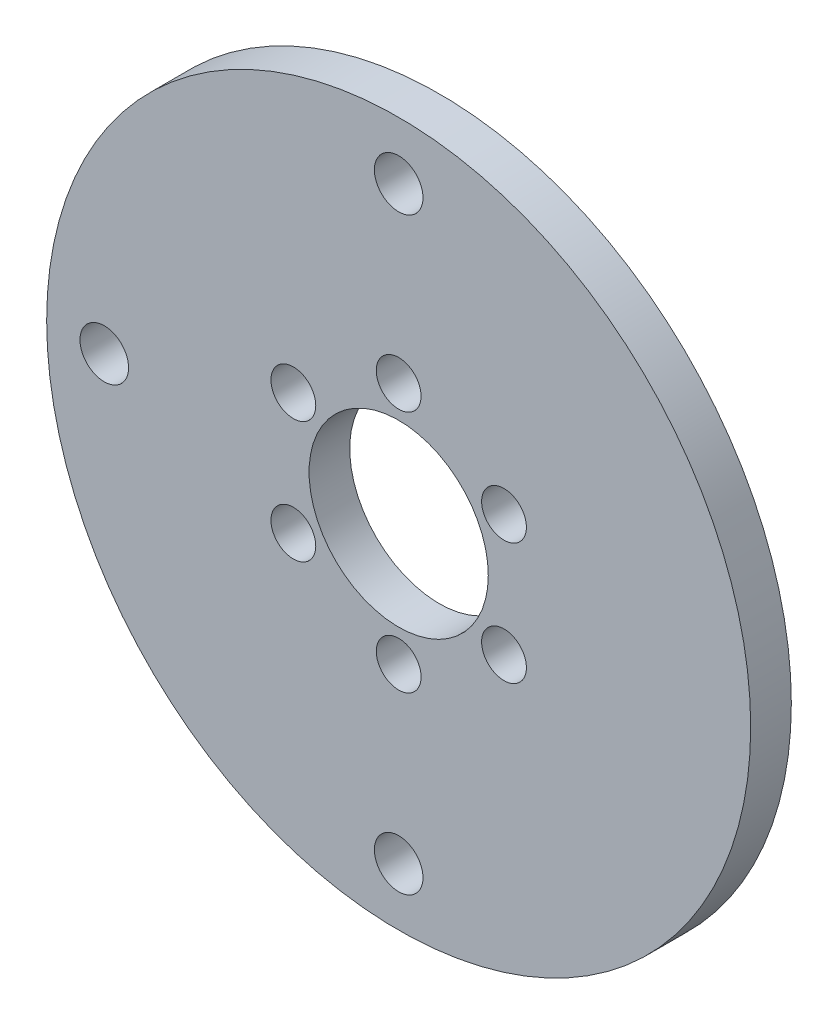
from build123d import *

# Parameters (mm, degrees)
SKETCH1_R           = 27.5
SKETCH1_R_2         = 7
SKETCH1_R_3         = 1.89865
SKETCH1_R_4         = 1.75
BOSS_EXTRUDE1_DEPTH = 3.175


with BuildPart() as part:
    # Sketch1 → Boss-Extrude1 (new body)
    with BuildSketch(Plane.XY):
        Circle(SKETCH1_R)
        Circle(SKETCH1_R_2, mode=Mode.SUBTRACT)
        with Locations((0, 23)):
            Circle(SKETCH1_R_3, mode=Mode.SUBTRACT)
        with Locations((0, -23)):
            Circle(SKETCH1_R_3, mode=Mode.SUBTRACT)
        with Locations((-23, 0)):
            Circle(SKETCH1_R_3, mode=Mode.SUBTRACT)
        with Locations((0, 9.5)):
            Circle(SKETCH1_R_4, mode=Mode.SUBTRACT)
        with Locations((8.227241336, 4.75)):
            Circle(SKETCH1_R_4, mode=Mode.SUBTRACT)
        with Locations((8.227241336, -4.75)):
            Circle(SKETCH1_R_4, mode=Mode.SUBTRACT)
        with Locations((0, -9.5)):
            Circle(SKETCH1_R_4, mode=Mode.SUBTRACT)
        with Locations((-8.227241336, -4.75)):
            Circle(SKETCH1_R_4, mode=Mode.SUBTRACT)
        with Locations((-8.227241336, 4.75)):
            Circle(SKETCH1_R_4, mode=Mode.SUBTRACT)
    extrude(amount=BOSS_EXTRUDE1_DEPTH)


solid = part.part
